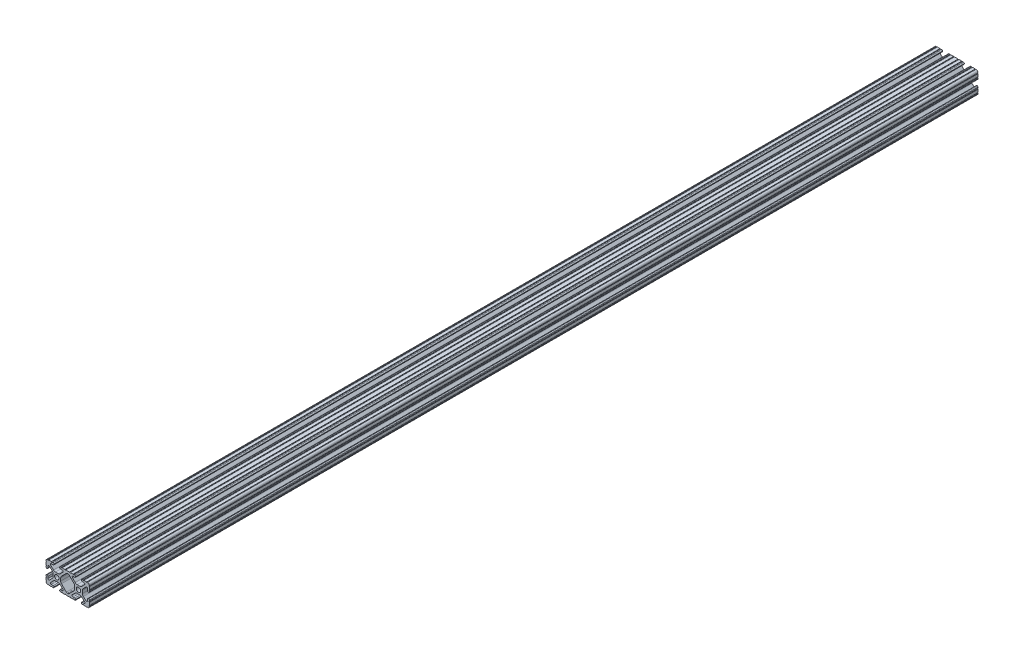
from build123d import *

# Parameters (mm, degrees)
SKETCH1_R           = 2.6035
BOSS_EXTRUDE1_DEPTH = 520.7


with BuildPart() as part:
    # Sketch1 → Boss-Extrude1 (new body, symmetric)
    with BuildSketch(Plane.XY):
        with BuildLine():
            Line((18.01710265, 12.7), (16.98745015, 12.7))
            ThreePointArc((16.98745015, 12.7), (16.245730386, 12.392769614), (15.9385, 11.65104985))
            Line((15.9385, 11.65104985), (15.9385, 11.53922))
            ThreePointArc((15.9385, 11.53922), (16.245750844, 10.797450844), (16.98752, 10.4902))
            Line((16.98752, 10.4902), (19.116384363, 10.4902))
            ThreePointArc((19.116384363, 10.4902), (20.052502933, 9.869096983), (19.844087081, 8.765172272))
            Line((19.844087081, 8.765172272), (16.618993479, 5.455112286))
            ThreePointArc((16.618993479, 5.455112286), (15.578994274, 4.745442459), (14.344932584, 4.4958))
            Line((14.344932584, 4.4958), (11.083317835, 4.4958))
            ThreePointArc((11.083317835, 4.4958), (9.854330953, 4.743306833), (8.816955189, 5.447238587))
            Line((8.816955189, 5.447238587), (5.564154119, 8.762652677))
            ThreePointArc((5.564154119, 8.762652677), (5.352591412, 9.867473037), (6.289393385, 10.4902))
            Line((6.289393385, 10.4902), (8.41248, 10.4902))
            ThreePointArc((8.41248, 10.4902), (9.154249156, 10.797450844), (9.4615, 11.53922))
            Line((9.4615, 11.53922), (9.4615, 11.65104985))
            ThreePointArc((9.4615, 11.65104985), (9.154269614, 12.392769614), (8.41254985, 12.7))
            Line((8.41254985, 12.7), (7.38288465, 12.7))
            ThreePointArc((7.38288465, 12.7), (6.87488465, 12.192), (6.36688465, 12.7))
            Line((6.36688465, 12.7), (3.14958095, 12.7))
            ThreePointArc((3.14958095, 12.7), (2.64158095, 12.192), (2.13358095, 12.7))
            Line((2.13358095, 12.7), (-2.13358095, 12.7))
            ThreePointArc((-2.13358095, 12.7), (-2.64158095, 12.192), (-3.14958095, 12.7))
            Line((-3.14958095, 12.7), (-6.36689735, 12.7))
            ThreePointArc((-6.36689735, 12.7), (-6.87489735, 12.192), (-7.38289735, 12.7))
            Line((-7.38289735, 12.7), (-8.41254985, 12.7))
            ThreePointArc((-8.41254985, 12.7), (-9.154269614, 12.392769614), (-9.4615, 11.65104985))
            Line((-9.4615, 11.65104985), (-9.4615, 11.53922))
            ThreePointArc((-9.4615, 11.53922), (-9.154249156, 10.797450844), (-8.41248, 10.4902))
            Line((-8.41248, 10.4902), (-6.283641037, 10.4902))
            ThreePointArc((-6.283641037, 10.4902), (-5.297291557, 9.829633109), (-5.532576693, 8.666071843))
            Line((-5.532576693, 8.666071843), (-8.809985098, 5.416263103))
            ThreePointArc((-8.809985098, 5.416263103), (-9.836720513, 4.734920264), (-11.045536121, 4.4958))
            Line((-11.045536121, 4.4958), (-14.354463879, 4.4958))
            ThreePointArc((-14.354463879, 4.4958), (-15.563279487, 4.734920264), (-16.590014902, 5.416263103))
            Line((-16.590014902, 5.416263103), (-19.867423307, 8.666071843))
            ThreePointArc((-19.867423307, 8.666071843), (-20.102708443, 9.829633109), (-19.116358963, 10.4902))
            Line((-19.116358963, 10.4902), (-16.98752, 10.4902))
            ThreePointArc((-16.98752, 10.4902), (-16.245750844, 10.797450844), (-15.9385, 11.53922))
            Line((-15.9385, 11.53922), (-15.9385, 11.65104985))
            ThreePointArc((-15.9385, 11.65104985), (-16.245730386, 12.392769614), (-16.98745015, 12.7))
            Line((-16.98745015, 12.7), (-18.01711535, 12.7))
            ThreePointArc((-18.01711535, 12.7), (-18.52511535, 12.192), (-19.03311535, 12.7))
            Line((-19.03311535, 12.7), (-22.2504, 12.7))
            ThreePointArc((-22.2504, 12.7), (-22.758323491, 12.192000006), (-23.266399977, 12.699846982))
            ThreePointArc((-23.266399977, 12.699846982), (-24.782522516, 12.082522516), (-25.399846982, 10.566399977))
            ThreePointArc((-25.399846982, 10.566399977), (-24.892000006, 10.058323491), (-25.4, 9.5504))
            Line((-25.4, 9.5504), (-25.4, 6.3330836))
            ThreePointArc((-25.4, 6.3330836), (-24.892, 5.8250836), (-25.4, 5.3170836))
            Line((-25.4, 5.3170836), (-25.4, 4.237520184))
            ThreePointArc((-25.4, 4.237520184), (-25.107393763, 3.531106237), (-24.400979816, 3.2385))
            Line((-24.400979816, 3.2385), (-24.23922, 3.2385))
            ThreePointArc((-24.23922, 3.2385), (-23.497450844, 3.545750844), (-23.1902, 4.28752))
            Line((-23.1902, 4.28752), (-23.1902, 6.334741132))
            ThreePointArc((-23.1902, 6.334741132), (-22.556026952, 7.286023527), (-21.434002553, 7.066535717))
            Line((-21.434002553, 7.066535717), (-18.147950853, 3.808156468))
            ThreePointArc((-18.147950853, 3.808156468), (-17.452759693, 2.774838327), (-17.208501877, 1.553619571))
            Line((-17.208501877, 1.553619571), (-17.208501877, -1.695179196))
            ThreePointArc((-17.208501877, -1.695179196), (-17.450738657, -2.911536421), (-18.140486065, -3.942289578))
            Line((-18.140486065, -3.942289578), (-21.431579576, -7.227386226))
            ThreePointArc((-21.431579576, -7.227386226), (-22.55444896, -7.449940594), (-23.1902, -6.498002195))
            Line((-23.1902, -6.498002195), (-23.1902, -4.28752))
            ThreePointArc((-23.1902, -4.28752), (-23.497450844, -3.545750844), (-24.23922, -3.2385))
            Line((-24.23922, -3.2385), (-24.35098, -3.2385))
            ThreePointArc((-24.35098, -3.2385), (-25.092749156, -3.545750844), (-25.4, -4.28752))
            Line((-25.4, -4.28752), (-25.4, -5.3171344))
            ThreePointArc((-25.4, -5.3171344), (-24.892, -5.8251344), (-25.4, -6.3331344))
            Line((-25.4, -6.3331344), (-25.4, -9.5504))
            ThreePointArc((-25.4, -9.5504), (-24.892000006, -10.058323491), (-25.399846982, -10.566399977))
            ThreePointArc((-25.399846982, -10.566399977), (-24.782522516, -12.082522516), (-23.266399977, -12.699846982))
            ThreePointArc((-23.266399977, -12.699846982), (-22.758323491, -12.192000006), (-22.2504, -12.7))
            Line((-22.2504, -12.7), (-19.03308995, -12.7))
            ThreePointArc((-19.03308995, -12.7), (-18.52508995, -12.192), (-18.01708995, -12.7))
            Line((-18.01708995, -12.7), (-16.9874692, -12.7))
            ThreePointArc((-16.9874692, -12.7), (-16.245700044, -12.392749156), (-15.9384492, -11.65098))
            Line((-15.9384492, -11.65098), (-15.9384492, -11.53922))
            ThreePointArc((-15.9384492, -11.53922), (-16.245700044, -10.797450844), (-16.9874692, -10.4902))
            Line((-16.9874692, -10.4902), (-19.116358963, -10.4902))
            ThreePointArc((-19.116358963, -10.4902), (-20.055197748, -9.862578342), (-19.834124023, -8.755124678))
            Line((-19.834124023, -8.755124678), (-16.49660751, -5.423689618))
            ThreePointArc((-16.49660751, -5.423689618), (-15.467274017, -4.736928798), (-14.253591699, -4.4958))
            Line((-14.253591699, -4.4958), (-11.146408301, -4.4958))
            ThreePointArc((-11.146408301, -4.4958), (-9.932725983, -4.736928798), (-8.90339249, -5.423689618))
            Line((-8.90339249, -5.423689618), (-5.565875977, -8.755124678))
            ThreePointArc((-5.565875977, -8.755124678), (-5.344802252, -9.862578342), (-6.283641037, -10.4902))
            Line((-6.283641037, -10.4902), (-8.4125308, -10.4902))
            ThreePointArc((-8.4125308, -10.4902), (-9.154299956, -10.797450844), (-9.4615508, -11.53922))
            Line((-9.4615508, -11.53922), (-9.4615508, -11.65098))
            ThreePointArc((-9.4615508, -11.65098), (-9.154299956, -12.392749156), (-8.4125308, -12.7))
            Line((-8.4125308, -12.7), (-7.38287195, -12.7))
            ThreePointArc((-7.38287195, -12.7), (-6.87487195, -12.192), (-6.36687195, -12.7))
            Line((-6.36687195, -12.7), (-3.14960635, -12.7))
            ThreePointArc((-3.14960635, -12.7), (-2.64160635, -12.192), (-2.13360635, -12.7))
            Line((-2.13360635, -12.7), (2.13360635, -12.7))
            ThreePointArc((2.13360635, -12.7), (2.64159365, -12.1920127), (3.14958095, -12.7))
            Line((3.14958095, -12.7), (6.36691005, -12.7))
            ThreePointArc((6.36691005, -12.7), (6.87491005, -12.192), (7.38291005, -12.7))
            Line((7.38291005, -12.7), (8.4125308, -12.7))
            ThreePointArc((8.4125308, -12.7), (9.154299956, -12.392749156), (9.4615508, -11.65098))
            Line((9.4615508, -11.65098), (9.4615508, -11.53922))
            ThreePointArc((9.4615508, -11.53922), (9.154299956, -10.797450844), (8.4125308, -10.4902))
            Line((8.4125308, -10.4902), (6.289393385, -10.4902))
            ThreePointArc((6.289393385, -10.4902), (5.231590322, -9.783049717), (5.480677245, -8.535265862))
            Line((5.480677245, -8.535265862), (8.597933595, -5.423689618))
            ThreePointArc((8.597933595, -5.423689618), (9.627267088, -4.736928798), (10.840949406, -4.4958))
            Line((10.840949406, -4.4958), (14.102564155, -4.4958))
            ThreePointArc((14.102564155, -4.4958), (15.215927525, -4.697410182), (16.187895372, -5.276636531))
            Line((16.187895372, -5.276636531), (19.868247549, -8.482246082))
            ThreePointArc((19.868247549, -8.482246082), (20.188435806, -9.746879864), (19.116384363, -10.4902))
            Line((19.116384363, -10.4902), (16.9874692, -10.4902))
            ThreePointArc((16.9874692, -10.4902), (16.245700044, -10.797450844), (15.9384492, -11.53922))
            Line((15.9384492, -11.53922), (15.9384492, -11.65098))
            ThreePointArc((15.9384492, -11.65098), (16.245700044, -12.392749156), (16.9874692, -12.7))
            Line((16.9874692, -12.7), (18.01710265, -12.7))
            ThreePointArc((18.01710265, -12.7), (18.52510265, -12.192), (19.03310265, -12.7))
            Line((19.03310265, -12.7), (22.2504, -12.7))
            ThreePointArc((22.2504, -12.7), (22.758323491, -12.192000006), (23.266399977, -12.699846982))
            ThreePointArc((23.266399977, -12.699846982), (24.782522516, -12.082522516), (25.399846982, -10.566399977))
            ThreePointArc((25.399846982, -10.566399977), (24.892000006, -10.058323492), (25.4, -9.550400001))
            Line((25.4, -9.550400001), (25.4, -6.333083592))
            ThreePointArc((25.4, -6.333083592), (24.892000001, -5.825083593), (25.4, -5.317083593))
            Line((25.4, -5.317083593), (25.4, -4.237520184))
            ThreePointArc((25.4, -4.237520184), (25.107393763, -3.531106237), (24.400979816, -3.2385))
            Line((24.400979816, -3.2385), (24.189220184, -3.2385))
            ThreePointArc((24.189220184, -3.2385), (23.482806237, -3.531106237), (23.1902, -4.237520184))
            Line((23.1902, -4.237520184), (23.1902, -6.155876159))
            ThreePointArc((23.1902, -6.155876159), (22.62232736, -7.038258539), (21.583974541, -6.886926384))
            Line((21.583974541, -6.886926384), (18.29817066, -4.024970844))
            ThreePointArc((18.29817066, -4.024970844), (17.493730985, -2.946044689), (17.208501877, -1.630807374))
            Line((17.208501877, -1.630807374), (17.208501877, 1.630807374))
            ThreePointArc((17.208501877, 1.630807374), (17.442348332, 2.82673414), (18.109440981, 3.846495088))
            Line((18.109440981, 3.846495088), (21.526346532, 7.353420386))
            ThreePointArc((21.526346532, 7.353420386), (22.585896263, 7.574939077), (23.1902, 6.676867167))
            Line((23.1902, 6.676867167), (23.1902, 4.237520184))
            ThreePointArc((23.1902, 4.237520184), (23.482806237, 3.531106237), (24.189220184, 3.2385))
            Line((24.189220184, 3.2385), (24.400979816, 3.2385))
            ThreePointArc((24.400979816, 3.2385), (25.107393763, 3.531106237), (25.4, 4.237520184))
            Line((25.4, 4.237520184), (25.4, 5.3170836))
            ThreePointArc((25.4, 5.3170836), (24.891949193, 5.825134407), (25.4, 6.333185215))
            Line((25.4, 6.333185215), (25.4, 9.550400015))
            ThreePointArc((25.4, 9.550400015), (24.892000013, 10.058323498), (25.399846982, 10.566399977))
            ThreePointArc((25.399846982, 10.566399977), (24.782522516, 12.082522516), (23.266399977, 12.699846982))
            ThreePointArc((23.266399977, 12.699846982), (22.758323491, 12.192000006), (22.2504, 12.7))
            Line((22.2504, 12.7), (19.03310265, 12.7))
            ThreePointArc((19.03310265, 12.7), (18.52510265, 12.192), (18.01710265, 12.7))
        make_face()
        with Locations((-12.7, 0)):
            Circle(SKETCH1_R, mode=Mode.SUBTRACT)
        with Locations((12.7, 0)):
            Circle(SKETCH1_R, mode=Mode.SUBTRACT)
        with BuildLine():
            Line((-7.259513935, -3.869413038), (-1.545748891, -9.572766749))
            ThreePointArc((-1.545748891, -9.572766749), (-1.035199478, -9.913400116), (-0.433213048, -10.033))
            Line((-0.433213048, -10.033), (0.433213048, -10.033))
            ThreePointArc((0.433213048, -10.033), (1.035199478, -9.913400116), (1.545748891, -9.572766749))
            Line((1.545748891, -9.572766749), (7.259513935, -3.869413038))
            ThreePointArc((7.259513935, -3.869413038), (7.949261343, -2.838659881), (8.191498123, -1.622302656))
            Line((8.191498123, -1.622302656), (8.191498123, 1.622302656))
            ThreePointArc((8.191498123, 1.622302656), (7.955573352, 2.823327967), (7.282860769, 3.845864069))
            Line((7.282860769, 3.845864069), (1.675572808, 9.561086461))
            ThreePointArc((1.675572808, 9.561086461), (1.161034429, 9.910236611), (0.551456936, 10.033))
            Line((0.551456936, 10.033), (-0.395199982, 10.033))
            ThreePointArc((-0.395199982, 10.033), (-0.994772524, 9.914396349), (-1.50403329, 9.576450301))
            Line((-1.50403329, 9.576450301), (-7.252049147, 3.876839553))
            ThreePointArc((-7.252049147, 3.876839553), (-7.947240307, 2.843521412), (-8.191498123, 1.622302656))
            Line((-8.191498123, 1.622302656), (-8.191498123, -1.622302656))
            ThreePointArc((-8.191498123, -1.622302656), (-7.949261343, -2.838659881), (-7.259513935, -3.869413038))
        make_face(mode=Mode.SUBTRACT)
    extrude(amount=BOSS_EXTRUDE1_DEPTH, both=True)


solid = part.part
